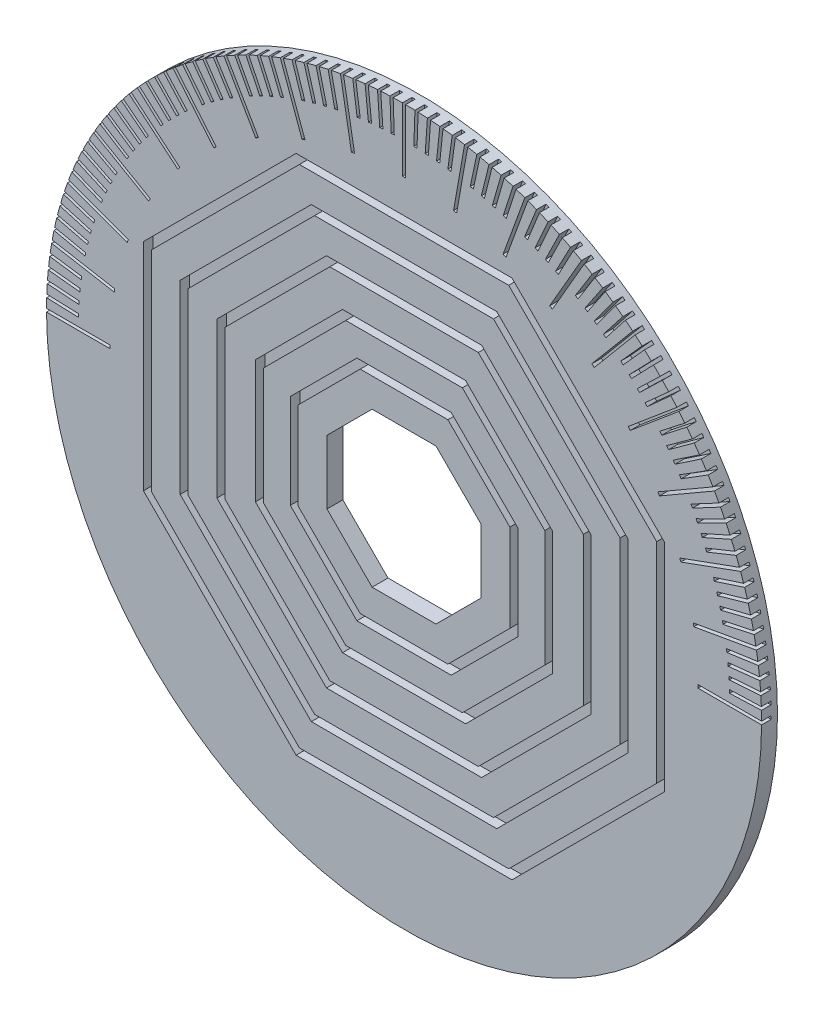
from build123d import *

# Parameters (mm, degrees)
SKETCH_1_R          = 45
EXTRUDE_1_DEPTH     = 2
CUT_EXTRUDE_1_DEPTH = 1.2
CUT_EXTRUDE_2_DEPTH = 1.2
SKETCH_6_W          = 4
SKETCH_6_H          = 0.4
SKETCH_6_W_2        = 0.4
SKETCH_6_H_2        = 4
CUT_EXTRUDE_5_DEPTH = 1.2
SKETCH_4_W          = 8
SKETCH_4_H          = 0.4
SKETCH_4_W_2        = 0.4
SKETCH_4_H_2        = 8
CUT_EXTRUDE_7_DEPTH = 1.2
CUT_EXTRUDE_8_DEPTH = 1.8


with BuildPart() as part:
    # 스케치1 → 보스-돌출1 (new body)
    with BuildSketch(Plane.XY):
        Circle(SKETCH_1_R)
    extrude(amount=EXTRUDE_1_DEPTH)

    # 스케치2 → 컷-돌출1 (cut)
    with BuildSketch(Plane.XY.offset(2)):
        Polygon((32.797723404, 13.585261849), (13.585261849, 32.797723404), (-13.585261849, 32.797723404), (-32.797723404, 13.585261849), (-32.797723404, -13.585261849), (-13.585261849, -32.797723404), (13.585261849, -32.797723404), (32.797723404, -13.585261849), align=None)
        Polygon((13.171048287, 31.797723404), (-13.171048287, 31.797723404), (-31.797723404, 13.171048287), (-31.797723404, -13.171048287), (-13.171048287, -31.797723404), (13.171048287, -31.797723404), (31.797723404, -13.171048287), (31.797723404, 13.171048287), align=None, mode=Mode.SUBTRACT)
    extrude(amount=-CUT_EXTRUDE_1_DEPTH, mode=Mode.SUBTRACT)

    # 스케치3 → 컷-돌출2 (cut)
    with BuildSketch(Plane.XY.offset(2)):
        Polygon((-28.178325742, -11.671844687), (-11.671844687, -28.178325742), (11.671844687, -28.178325742), (28.178325742, -11.671844687), (28.178325742, 11.671844687), (11.671844687, 28.178325742), (-11.671844687, 28.178325742), (-28.178325742, 11.671844687), align=None)
        Polygon((-11.257631125, -27.178325742), (11.257631125, -27.178325742), (27.178325742, -11.257631125), (27.178325742, 11.257631125), (11.257631125, 27.178325742), (-11.257631125, 27.178325742), (-27.178325742, 11.257631125), (-27.178325742, -11.257631125), align=None, mode=Mode.SUBTRACT)
        Polygon((23.558928079, 9.758427525), (9.758427525, 23.558928079), (-9.758427525, 23.558928079), (-23.558928079, 9.758427525), (-23.558928079, -9.758427525), (-9.758427525, -23.558928079), (9.758427525, -23.558928079), (23.558928079, -9.758427525), align=None)
        Polygon((9.344213963, 22.558928079), (-9.344213963, 22.558928079), (-22.558928079, 9.344213963), (-22.558928079, -9.344213963), (-9.344213963, -22.558928079), (9.344213963, -22.558928079), (22.558928079, -9.344213963), (22.558928079, 9.344213963), align=None, mode=Mode.SUBTRACT)
        Polygon((18.708560533, 7.749339505), (7.749339505, 18.708560533), (-7.749339505, 18.708560533), (-18.708560533, 7.749339505), (-18.708560533, -7.749339505), (-7.749339505, -18.708560533), (7.749339505, -18.708560533), (18.708560533, -7.749339505), align=None)
        Polygon((7.335125943, 17.708560533), (-7.335125943, 17.708560533), (-17.708560533, 7.335125943), (-17.708560533, -7.335125943), (-7.335125943, -17.708560533), (7.335125943, -17.708560533), (17.708560533, -7.335125943), (17.708560533, 7.335125943), align=None, mode=Mode.SUBTRACT)
        Polygon((-14.320132754, -5.931593202), (-5.931593202, -14.320132754), (5.931593202, -14.320132754), (14.320132754, -5.931593202), (14.320132754, 5.931593202), (5.931593202, 14.320132754), (-5.931593202, 14.320132754), (-14.320132754, 5.931593202), align=None)
        Polygon((-5.517379639, -13.320132754), (5.517379639, -13.320132754), (13.320132754, -5.517379639), (13.320132754, 5.517379639), (5.517379639, 13.320132754), (-5.517379639, 13.320132754), (-13.320132754, 5.517379639), (-13.320132754, -5.517379639), align=None, mode=Mode.SUBTRACT)
        Polygon((-4.01817604, 9.700735091), (-9.700735091, 4.01817604), (-9.700735091, -4.01817604), (-4.01817604, -9.700735091), (4.01817604, -9.700735091), (9.700735091, -4.01817604), (9.700735091, 4.01817604), (4.01817604, 9.700735091), align=None)
    extrude(amount=-CUT_EXTRUDE_2_DEPTH, mode=Mode.SUBTRACT)

    # 스케치6 → 컷-돌출5 (cut)
    with BuildSketch(Plane.XY.offset(2)):
        with Locations((-43, 0)):
            Rectangle(SKETCH_6_W, SKETCH_6_H)
        Polygon((-44.965607317, 1.770355517), (-44.979567115, 1.370599186), (-40.982003807, 1.231001199), (-40.968044008, 1.63075753), align=None)
        Polygon((-44.876430967, 3.338554129), (-44.904333556, 2.939528508), (-40.914077355, 2.660502613), (-40.886174766, 3.059528234), align=None)
        Polygon((-44.732579599, 4.902685226), (-44.774390984, 4.504876468), (-40.796303403, 4.086762615), (-40.754492017, 4.484571373), align=None)
        Polygon((-44.534228473, 6.460843157), (-44.589897714, 6.064735929), (-40.628825439, 5.508043526), (-40.573156198, 5.904150753), align=None)
        Polygon((-44.28161925, 8.011129546), (-44.351078521, 7.617206444), (-40.411847509, 6.922613734), (-40.342388238, 7.316536835), align=None)
        Polygon((-43.975059695, 9.551655607), (-44.058224371, 9.160396567), (-40.145633968, 8.328749803), (-40.062469292, 8.720008844), align=None)
        Polygon((-43.614923303, 11.080544447), (-43.711692062, 10.692426157), (-39.830509156, 9.724738574), (-39.733740398, 10.112856865), align=None)
        Polygon((-43.201648846, 12.595933351), (-43.311903788, 12.211428673), (-39.466857005, 11.108879249), (-39.356602062, 11.493383928), align=None)
        Polygon((-42.735739834, 14.09597605), (-42.859346632, 13.715553444), (-39.055120567, 12.479485466), (-38.931513769, 12.859908073), align=None)
        Polygon((-42.217763907, 15.578844974), (-42.354571964, 15.202967925), (-38.595801481, 13.834887352), (-38.458993424, 14.210764401), align=None)
        Polygon((-41.648352137, 17.042733475), (-41.798194774, 16.671859933), (-38.089459356, 15.173433559), (-37.939616719, 15.544307101), align=None)
        Polygon((-41.028198265, 18.48585803), (-41.190892923, 18.120439847), (-37.536711092, 16.493493275), (-37.374016435, 16.858911458), align=None)
        Polygon((-40.358057854, 19.906460415), (-40.533406313, 19.546942796), (-36.938230128, 17.793458209), (-36.762881669, 18.152975828), align=None)
        Polygon((-39.638747366, 21.302809844), (-39.826535991, 20.949630807), (-36.29474562, 19.071744556), (-36.106956995, 19.424923593), align=None)
        Polygon((-38.87114317, 22.673205081), (-39.07114317, 22.326794919), (-35.607041555, 20.326794919), (-35.407041555, 20.673205081), align=None)
        Polygon((-38.056180474, 24.01597651), (-38.26814818, 23.676757271), (-34.875955795, 21.557080214), (-34.66398809, 21.896299453), align=None)
        Polygon((-37.194852184, 25.329488171), (-37.418529346, 24.997873142), (-34.102379055, 22.761101528), (-33.878701894, 23.092716557), align=None)
        Polygon((-36.288207696, 26.612139752), (-36.523321797, 26.288532954), (-33.28725382, 23.937391945), (-33.052139719, 24.260998743), align=None)
        Polygon((-35.337351617, 27.86236854), (-35.583616207, 27.547164239), (-32.431573193, 25.084518338), (-32.185308603, 25.399722639), align=None)
        Polygon((-34.343442418, 29.078651325), (-34.600557462, 28.772233547), (-31.53637969, 26.201083109), (-31.279264646, 26.507500886), align=None)
        Polygon((-33.307691025, 30.259506251), (-33.575343268, 29.962248321), (-30.602763966, 27.285725896), (-30.335111723, 27.582983826), align=None)
        Polygon((-32.231359341, 31.403494631), (-32.509222689, 31.115758711), (-29.631863488, 28.337125229), (-29.35400014, 28.624861149), align=None)
        Polygon((-31.115758711, 32.509222689), (-31.403494631, 32.231359341), (-28.624861149, 29.35400014), (-28.337125229, 29.631863488), align=None)
        Polygon((-29.962248321, 33.575343268), (-30.259506251, 33.307691025), (-27.582983826, 30.335111723), (-27.285725896, 30.602763966), align=None)
        Polygon((-28.772233547, 34.600557462), (-29.078651325, 34.343442418), (-26.507500886, 31.279264646), (-26.201083109, 31.53637969), align=None)
        Polygon((-27.547164239, 35.583616207), (-27.86236854, 35.337351617), (-25.399722639, 32.185308603), (-25.084518338, 32.431573193), align=None)
        Polygon((-26.288532954, 36.523321797), (-26.612139752, 36.288207696), (-24.260998743, 33.052139719), (-23.937391945, 33.28725382), align=None)
        Polygon((-24.997873142, 37.418529346), (-25.329488171, 37.194852184), (-23.092716557, 33.878701894), (-22.761101528, 34.102379055), align=None)
        Polygon((-23.676757271, 38.26814818), (-24.01597651, 38.056180474), (-21.896299453, 34.66398809), (-21.557080214, 34.875955795), align=None)
        Polygon((-22.326794919, 39.07114317), (-22.673205081, 38.87114317), (-20.673205081, 35.407041555), (-20.326794919, 35.607041555), align=None)
        Polygon((-20.949630807, 39.826535991), (-21.302809844, 39.638747366), (-19.424923593, 36.106956995), (-19.071744556, 36.29474562), align=None)
        Polygon((-19.546942796, 40.533406313), (-19.906460415, 40.358057854), (-18.152975828, 36.762881669), (-17.793458209, 36.938230128), align=None)
        Polygon((-18.120439847, 41.190892923), (-18.48585803, 41.028198265), (-16.858911458, 37.374016435), (-16.493493275, 37.536711092), align=None)
        Polygon((-16.671859933, 41.798194774), (-17.042733475, 41.648352137), (-15.544307101, 37.939616719), (-15.173433559, 38.089459356), align=None)
        Polygon((-15.202967925, 42.354571964), (-15.578844974, 42.217763907), (-14.210764401, 38.458993424), (-13.834887352, 38.595801481), align=None)
        Polygon((-13.715553444, 42.859346632), (-14.09597605, 42.735739834), (-12.859908073, 38.931513769), (-12.479485466, 39.055120567), align=None)
        Polygon((-12.211428673, 43.311903788), (-12.595933351, 43.201648846), (-11.493383928, 39.356602062), (-11.108879249, 39.466857005), align=None)
        Polygon((-10.692426157, 43.711692062), (-11.080544447, 43.614923303), (-10.112856865, 39.733740398), (-9.724738574, 39.830509156), align=None)
        Polygon((-9.160396567, 44.058224371), (-9.551655607, 43.975059695), (-8.720008844, 40.062469292), (-8.328749803, 40.145633968), align=None)
        Polygon((-7.617206444, 44.351078521), (-8.011129546, 44.28161925), (-7.316536835, 40.342388238), (-6.922613734, 40.411847509), align=None)
        Polygon((-6.064735929, 44.589897714), (-6.460843157, 44.534228473), (-5.904150753, 40.573156198), (-5.508043526, 40.628825439), align=None)
        Polygon((-4.504876468, 44.774390984), (-4.902685226, 44.732579599), (-4.484571373, 40.754492017), (-4.086762615, 40.796303403), align=None)
        Polygon((-2.939528508, 44.904333556), (-3.338554129, 44.876430967), (-3.059528234, 40.886174766), (-2.660502613, 40.914077355), align=None)
        Polygon((-1.370599186, 44.979567115), (-1.770355517, 44.965607317), (-1.63075753, 40.968044008), (-1.231001199, 40.982003807), align=None)
        with Locations((0, 43)):
            Rectangle(SKETCH_6_W_2, SKETCH_6_H_2)
        Polygon((1.770355517, 44.965607317), (1.370599186, 44.979567115), (1.231001199, 40.982003807), (1.63075753, 40.968044008), align=None)
        Polygon((3.338554129, 44.876430967), (2.939528508, 44.904333556), (2.660502613, 40.914077355), (3.059528234, 40.886174766), align=None)
        Polygon((4.902685226, 44.732579599), (4.504876468, 44.774390984), (4.086762615, 40.796303403), (4.484571373, 40.754492017), align=None)
        Polygon((6.460843157, 44.534228473), (6.064735929, 44.589897714), (5.508043526, 40.628825439), (5.904150753, 40.573156198), align=None)
        Polygon((8.011129546, 44.28161925), (7.617206444, 44.351078521), (6.922613734, 40.411847509), (7.316536835, 40.342388238), align=None)
        Polygon((9.551655607, 43.975059695), (9.160396567, 44.058224371), (8.328749803, 40.145633968), (8.720008844, 40.062469292), align=None)
        Polygon((11.080544447, 43.614923303), (10.692426157, 43.711692062), (9.724738574, 39.830509156), (10.112856865, 39.733740398), align=None)
        Polygon((12.595933351, 43.201648846), (12.211428673, 43.311903788), (11.108879249, 39.466857005), (11.493383928, 39.356602062), align=None)
        Polygon((14.09597605, 42.735739834), (13.715553444, 42.859346632), (12.479485466, 39.055120567), (12.859908073, 38.931513769), align=None)
        Polygon((15.578844974, 42.217763907), (15.202967925, 42.354571964), (13.834887352, 38.595801481), (14.210764401, 38.458993424), align=None)
        Polygon((17.042733475, 41.648352137), (16.671859933, 41.798194774), (15.173433559, 38.089459356), (15.544307101, 37.939616719), align=None)
        Polygon((18.48585803, 41.028198265), (18.120439847, 41.190892923), (16.493493275, 37.536711092), (16.858911458, 37.374016435), align=None)
        Polygon((19.906460415, 40.358057854), (19.546942796, 40.533406313), (17.793458209, 36.938230128), (18.152975828, 36.762881669), align=None)
        Polygon((21.302809844, 39.638747366), (20.949630807, 39.826535991), (19.071744556, 36.29474562), (19.424923593, 36.106956995), align=None)
        Polygon((22.673205081, 38.87114317), (22.326794919, 39.07114317), (20.326794919, 35.607041555), (20.673205081, 35.407041555), align=None)
        Polygon((24.01597651, 38.056180474), (23.676757271, 38.26814818), (21.557080214, 34.875955795), (21.896299453, 34.66398809), align=None)
        Polygon((25.329488171, 37.194852184), (24.997873142, 37.418529346), (22.761101528, 34.102379055), (23.092716557, 33.878701894), align=None)
        Polygon((26.612139752, 36.288207696), (26.288532954, 36.523321797), (23.937391945, 33.28725382), (24.260998743, 33.052139719), align=None)
        Polygon((27.86236854, 35.337351617), (27.547164239, 35.583616207), (25.084518338, 32.431573193), (25.399722639, 32.185308603), align=None)
        Polygon((29.078651325, 34.343442418), (28.772233547, 34.600557462), (26.201083109, 31.53637969), (26.507500886, 31.279264646), align=None)
        Polygon((30.259506251, 33.307691025), (29.962248321, 33.575343268), (27.285725896, 30.602763966), (27.582983826, 30.335111723), align=None)
        Polygon((31.403494631, 32.231359341), (31.115758711, 32.509222689), (28.337125229, 29.631863488), (28.624861149, 29.35400014), align=None)
        Polygon((32.509222689, 31.115758711), (32.231359341, 31.403494631), (29.35400014, 28.624861149), (29.631863488, 28.337125229), align=None)
        Polygon((33.575343268, 29.962248321), (33.307691025, 30.259506251), (30.335111723, 27.582983826), (30.602763966, 27.285725896), align=None)
        Polygon((34.600557462, 28.772233547), (34.343442418, 29.078651325), (31.279264646, 26.507500886), (31.53637969, 26.201083109), align=None)
        Polygon((35.583616207, 27.547164239), (35.337351617, 27.86236854), (32.185308603, 25.399722639), (32.431573193, 25.084518338), align=None)
        Polygon((36.523321797, 26.288532954), (36.288207696, 26.612139752), (33.052139719, 24.260998743), (33.28725382, 23.937391945), align=None)
        Polygon((37.418529346, 24.997873142), (37.194852184, 25.329488171), (33.878701894, 23.092716557), (34.102379055, 22.761101528), align=None)
        Polygon((38.26814818, 23.676757271), (38.056180474, 24.01597651), (34.66398809, 21.896299453), (34.875955795, 21.557080214), align=None)
        Polygon((39.07114317, 22.326794919), (38.87114317, 22.673205081), (35.407041555, 20.673205081), (35.607041555, 20.326794919), align=None)
        Polygon((39.826535991, 20.949630807), (39.638747366, 21.302809844), (36.106956995, 19.424923593), (36.29474562, 19.071744556), align=None)
        Polygon((40.533406313, 19.546942796), (40.358057854, 19.906460415), (36.762881669, 18.152975828), (36.938230128, 17.793458209), align=None)
        Polygon((41.190892923, 18.120439847), (41.028198265, 18.48585803), (37.374016435, 16.858911458), (37.536711092, 16.493493275), align=None)
        Polygon((41.798194774, 16.671859933), (41.648352137, 17.042733475), (37.939616719, 15.544307101), (38.089459356, 15.173433559), align=None)
        Polygon((42.354571964, 15.202967926), (42.217763907, 15.578844974), (38.458993424, 14.210764401), (38.595801481, 13.834887352), align=None)
        Polygon((42.859346632, 13.715553444), (42.735739834, 14.09597605), (38.931513769, 12.859908073), (39.055120567, 12.479485466), align=None)
        Polygon((43.311903788, 12.211428673), (43.201648846, 12.595933351), (39.356602062, 11.493383928), (39.466857005, 11.108879249), align=None)
        Polygon((43.711692062, 10.692426157), (43.614923303, 11.080544447), (39.733740398, 10.112856865), (39.830509156, 9.724738574), align=None)
        Polygon((44.058224371, 9.160396567), (43.975059695, 9.551655607), (40.062469292, 8.720008844), (40.145633968, 8.328749803), align=None)
        Polygon((44.351078521, 7.617206444), (44.28161925, 8.011129546), (40.342388238, 7.316536835), (40.411847509, 6.922613734), align=None)
        Polygon((44.589897714, 6.064735929), (44.534228473, 6.460843157), (40.573156198, 5.904150753), (40.628825439, 5.508043526), align=None)
        Polygon((44.774390984, 4.504876468), (44.732579599, 4.902685226), (40.754492017, 4.484571373), (40.796303403, 4.086762615), align=None)
        Polygon((44.904333556, 2.939528508), (44.876430967, 3.338554129), (40.886174766, 3.059528234), (40.914077355, 2.660502613), align=None)
        Polygon((44.979567115, 1.370599186), (44.965607317, 1.770355517), (40.968044008, 1.63075753), (40.982003807, 1.231001199), align=None)
        with Locations((43, 0)):
            Rectangle(SKETCH_6_W, SKETCH_6_H)
    extrude(amount=-CUT_EXTRUDE_5_DEPTH, mode=Mode.SUBTRACT)

    # 스케치4 → 컷-돌출7 (cut)
    with BuildSketch(Plane.XY.offset(2)):
        with Locations((-41, 0)):
            Rectangle(SKETCH_4_W, SKETCH_4_H)
        Polygon((-44.28161925, 8.011129546), (-44.351078521, 7.617206444), (-36.472616497, 6.228021023), (-36.403157226, 6.621944124), align=None)
        Polygon((-42.217763907, 15.578844974), (-42.354571964, 15.202967925), (-34.837030998, 12.466806779), (-34.70022294, 12.842683827), align=None)
        Polygon((-38.87114317, 22.673205081), (-39.07114317, 22.326794919), (-32.14293994, 18.326794919), (-31.94293994, 18.673205081), align=None)
        Polygon((-34.343442418, 29.078651325), (-34.600557462, 28.772233547), (-28.472201917, 23.62993267), (-28.215086873, 23.936350447), align=None)
        Polygon((-28.772233547, 34.600557462), (-29.078651325, 34.343442418), (-23.936350447, 28.215086873), (-23.62993267, 28.472201917), align=None)
        Polygon((-22.326794919, 39.07114317), (-22.673205081, 38.87114317), (-18.673205081, 31.94293994), (-18.326794919, 32.14293994), align=None)
        Polygon((-15.202967925, 42.354571964), (-15.578844974, 42.217763907), (-12.842683827, 34.70022294), (-12.466806779, 34.837030998), align=None)
        Polygon((-7.617206444, 44.351078521), (-8.011129546, 44.28161925), (-6.621944124, 36.403157226), (-6.228021023, 36.472616497), align=None)
        with Locations((0, 41)):
            Rectangle(SKETCH_4_W_2, SKETCH_4_H_2)
        Polygon((8.011129546, 44.28161925), (7.617206444, 44.351078521), (6.228021023, 36.472616497), (6.621944124, 36.403157226), align=None)
        Polygon((15.578844974, 42.217763907), (15.202967925, 42.354571964), (12.466806779, 34.837030998), (12.842683827, 34.70022294), align=None)
        Polygon((22.673205081, 38.87114317), (22.326794919, 39.07114317), (18.326794919, 32.14293994), (18.673205081, 31.94293994), align=None)
        Polygon((29.078651325, 34.343442418), (28.772233547, 34.600557462), (23.62993267, 28.472201917), (23.936350447, 28.215086873), align=None)
        Polygon((34.600557462, 28.772233547), (34.343442418, 29.078651325), (28.215086873, 23.936350447), (28.472201917, 23.62993267), align=None)
        Polygon((39.07114317, 22.326794919), (38.87114317, 22.673205081), (31.94293994, 18.673205081), (32.14293994, 18.326794919), align=None)
        Polygon((42.354571964, 15.202967925), (42.217763907, 15.578844974), (34.70022294, 12.842683827), (34.837030998, 12.466806779), align=None)
        Polygon((44.351078521, 7.617206444), (44.28161925, 8.011129546), (36.403157226, 6.621944124), (36.472616497, 6.228021023), align=None)
        with Locations((41, 0)):
            Rectangle(SKETCH_4_W, SKETCH_4_H)
    extrude(amount=-CUT_EXTRUDE_7_DEPTH, mode=Mode.SUBTRACT)

    # 스케치7 → 컷-돌출8 (cut, through all)
    with BuildSketch(Plane.XY.offset(0.8)):
        Polygon((4.01817604, 9.700735091), (-4.01817604, 9.700735091), (-9.700735091, 4.01817604), (-9.700735091, -4.01817604), (-4.01817604, -9.700735091), (4.01817604, -9.700735091), (9.700735091, -4.01817604), (9.700735091, 4.01817604), align=None)
    extrude(amount=-CUT_EXTRUDE_8_DEPTH, mode=Mode.SUBTRACT)


solid = part.part
